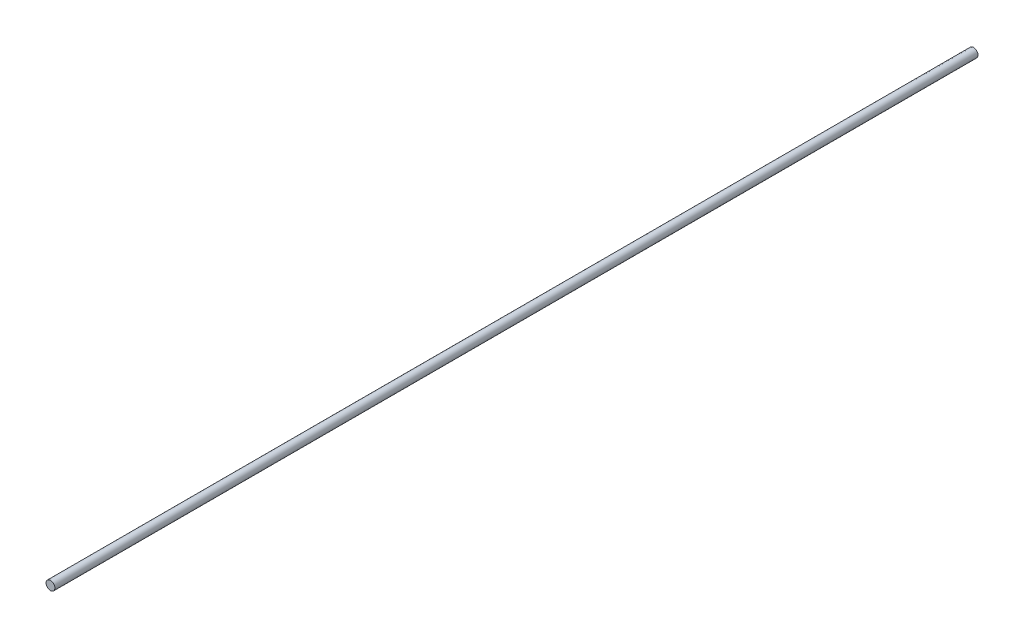
from build123d import *

# Parameters (mm, degrees)
SKETCH1_R                = 3.5
BOSS_EXTRUDE1_DEPTH      = 654.041228
BOSS_EXTRUDE1_DEPTH_BACK = 72.093972


with BuildPart() as part:
    # Sketch1 → Boss-Extrude1 (new body, two sides)
    with BuildSketch(Plane.XY) as boss_extrude1_sk:
        with Locations((86.996231173, -86.996231173)):
            Circle(SKETCH1_R)
    extrude(amount=BOSS_EXTRUDE1_DEPTH)
    extrude(boss_extrude1_sk.sketch, amount=-BOSS_EXTRUDE1_DEPTH_BACK)


solid = part.part
